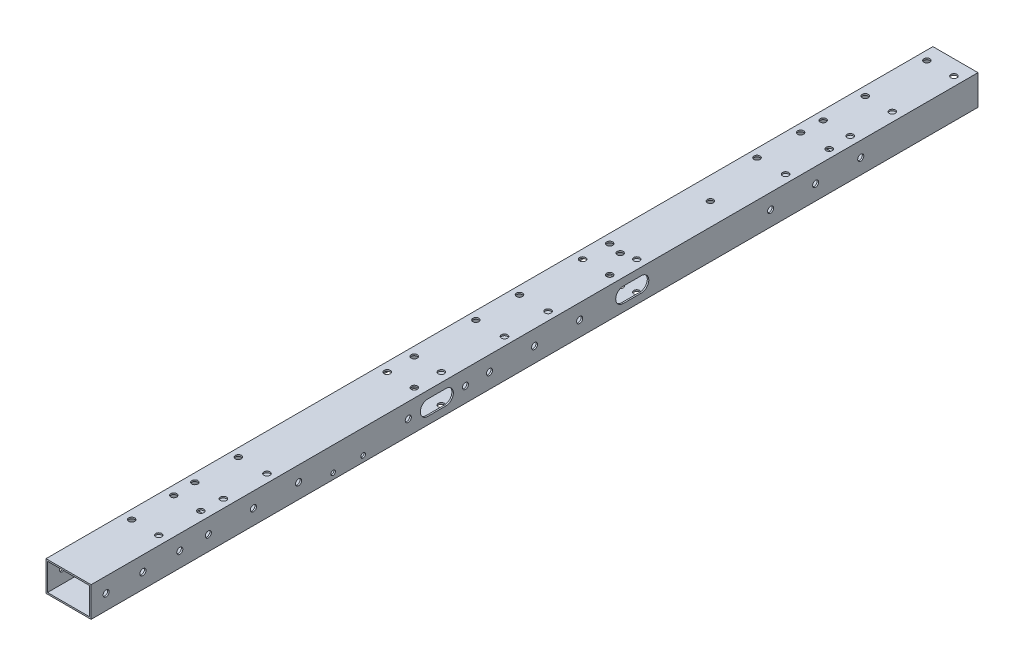
from build123d import *

# Parameters (mm, degrees)
SKETCH_1_W           = 30
SKETCH_1_H           = 20
SKETCH_1_W_2         = 28
SKETCH_1_H_2         = 18
EXTRUDE_1_DEPTH      = 295
SKETCH_5_R           = 2.025
CUT_EXTRUDE_4_DEPTH  = 5
SKETCH_7_R           = 3.8
CUT_EXTRUDE_5_DEPTH  = 5
SKETCH_11_R          = 2.025
CUT_EXTRUDE_9_DEPTH  = 113
SKETCH_18_R          = 2.025
CUT_EXTRUDE_16_DEPTH = 90
SKETCH_21_R          = 2.025
CUT_EXTRUDE_19_DEPTH = 126
SKETCH_22_R          = 2.025
CUT_EXTRUDE_20_DEPTH = 10
SKETCH_26_R          = 1.525
CUT_EXTRUDE_24_DEPTH = 10
SKETCH_27_R          = 1.525
CUT_EXTRUDE_25_DEPTH = 100
CUT_EXTRUDE_26_DEPTH = 100
SKETCH_31_R          = 2.025
CUT_EXTRUDE_29_DEPTH = 50
SKETCH_32_R          = 3.75
CUT_EXTRUDE_30_DEPTH = 10
SKETCH_36_R          = 2.025
CUT_EXTRUDE_33_DEPTH = 37
SKETCH_37_R          = 3.8
CUT_EXTRUDE_34_DEPTH = 10


with BuildPart() as part:
    # 草图1 → 凸台-拉伸1 (new, symmetric)
    with BuildSketch(Plane.XY):
        Rectangle(SKETCH_1_W, SKETCH_1_H)
        Rectangle(SKETCH_1_W_2, SKETCH_1_H_2, mode=Mode.SUBTRACT)
    extrude(amount=EXTRUDE_1_DEPTH, both=True)

    # 草图5 → 切除-拉伸4 (cut, symmetric)
    with BuildSketch(Plane.XZ.offset(-9)):
        with Locations((-9.5, -172.5)):
            Circle(SKETCH_5_R)
        with Locations((9.5, -172.5)):
            Circle(SKETCH_5_R)
        with Locations((-9.5, -201.5)):
            Circle(SKETCH_5_R)
        with Locations((9.5, -201.5)):
            Circle(SKETCH_5_R)
        with Locations((-9.5, -14.5)):
            Circle(SKETCH_5_R)
        with Locations((9.5, -14.5)):
            Circle(SKETCH_5_R)
        with Locations((-9.5, 14.5)):
            Circle(SKETCH_5_R)
        with Locations((9.5, 14.5)):
            Circle(SKETCH_5_R)
        with Locations((-9.5, 172.5)):
            Circle(SKETCH_5_R)
        with Locations((-9.5, 201.5)):
            Circle(SKETCH_5_R)
        with Locations((9.5, 201.5)):
            Circle(SKETCH_5_R)
        with Locations((9.5, 172.5)):
            Circle(SKETCH_5_R)
    extrude(amount=CUT_EXTRUDE_4_DEPTH, both=True, mode=Mode.SUBTRACT)

    # 草图7 → 切除-拉伸5 (cut, symmetric)
    with BuildSketch(Plane(origin=(0, -9, 0), x_dir=(1, 0, 0), z_dir=(0, 1, 0))):
        with Locations((-9.5, 201.5)):
            Circle(SKETCH_7_R)
        with Locations((9.5, 201.5)):
            Circle(SKETCH_7_R)
        with Locations((-9.5, 172.5)):
            Circle(SKETCH_7_R)
        with Locations((9.5, 172.5)):
            Circle(SKETCH_7_R)
        with Locations((-9.5, 14.5)):
            Circle(SKETCH_7_R)
        with Locations((9.5, 14.5)):
            Circle(SKETCH_7_R)
        with Locations((-9.5, -14.5)):
            Circle(SKETCH_7_R)
        with Locations((9.5, -14.5)):
            Circle(SKETCH_7_R)
        with Locations((-9.5, -172.5)):
            Circle(SKETCH_7_R)
        with Locations((9.5, -172.5)):
            Circle(SKETCH_7_R)
        with Locations((-9.5, -201.5)):
            Circle(SKETCH_7_R)
        with Locations((9.5, -201.5)):
            Circle(SKETCH_7_R)
    extrude(amount=CUT_EXTRUDE_5_DEPTH, both=True, mode=Mode.SUBTRACT)

    # 草图11 → 切除-拉伸9 (cut)
    with BuildSketch(Plane(origin=(15, 0, 0), x_dir=(0, 0, -1), z_dir=(1, 0, 0))):
        with Locations((217, 0)):
            Circle(SKETCH_11_R)
        with Locations((187, 0)):
            Circle(SKETCH_11_R)
        with Locations((157, 0)):
            Circle(SKETCH_11_R)
        with Locations((30, 0)):
            Circle(SKETCH_11_R)
        Circle(SKETCH_11_R)
        with Locations((-30, 0)):
            Circle(SKETCH_11_R)
        with Locations((-157, 0)):
            Circle(SKETCH_11_R)
        with Locations((-187, 0)):
            Circle(SKETCH_11_R)
        with Locations((-217, 0)):
            Circle(SKETCH_11_R)
        with Locations((-236, 0)):
            Circle(SKETCH_11_R)
        with Locations((-260.5, 0)):
            Circle(SKETCH_11_R)
        with Locations((-285, 0)):
            Circle(SKETCH_11_R)
    extrude(amount=-CUT_EXTRUDE_9_DEPTH, mode=Mode.SUBTRACT)

    # 草图18 → 切除-拉伸16 (cut)
    with BuildSketch(Plane.XZ.offset(10)):
        with Locations((-9, 74)):
            Circle(SKETCH_18_R)
        with Locations((9, 74)):
            Circle(SKETCH_18_R)
        with Locations((-9, 56)):
            Circle(SKETCH_18_R)
        with Locations((9, 56)):
            Circle(SKETCH_18_R)
    cut_extrude_16 = extrude(amount=-CUT_EXTRUDE_16_DEPTH, mode=Mode.SUBTRACT)

    # 镜向1: 切除-拉伸16 across plane
    add(cut_extrude_16.mirror(Plane.XY), mode=Mode.SUBTRACT)

    # 草图21 → 切除-拉伸19 (cut)
    with BuildSketch(Plane(origin=(15, 0, 0), x_dir=(0, 0, -1), z_dir=(1, 0, 0))):
        with Locations((-46, 0)):
            Circle(SKETCH_21_R)
        with Locations((-84, 0)):
            Circle(SKETCH_21_R)
    extrude(amount=-CUT_EXTRUDE_19_DEPTH, mode=Mode.SUBTRACT)

    # 草图22 → 切除-拉伸20 (cut)
    with BuildSketch(Plane(origin=(0, 10, 0), x_dir=(1, 0, 0), z_dir=(0, 1, 0))):
        with Locations((-9, 285)):
            Circle(SKETCH_22_R)
        with Locations((9, 285)):
            Circle(SKETCH_22_R)
    extrude(amount=-CUT_EXTRUDE_20_DEPTH, mode=Mode.SUBTRACT)

    # 草图26 → 切除-拉伸24 (cut)
    with BuildSketch(Plane.XZ.offset(10)):
        with Locations((-11, 124)):
            Circle(SKETCH_26_R)
        with Locations((-11, 144)):
            Circle(SKETCH_26_R)
        with Locations((11, 144)):
            Circle(SKETCH_26_R)
        with Locations((11, 124)):
            Circle(SKETCH_26_R)
    extrude(amount=-CUT_EXTRUDE_24_DEPTH, mode=Mode.SUBTRACT)

    # 草图27 → 切除-拉伸25 (cut)
    with BuildSketch(Plane.ZY.offset(15)):
        with Locations((134, -6)):
            Circle(SKETCH_27_R)
        with Locations((114, -6)):
            Circle(SKETCH_27_R)
    extrude(amount=-CUT_EXTRUDE_25_DEPTH, mode=Mode.SUBTRACT)

    # 草图28 → 切除-拉伸26 (cut)
    with BuildSketch(Plane(origin=(15, 0, 0), x_dir=(0, 0, -1), z_dir=(1, 0, 0))):
        with BuildLine():
            Line((-71, 5), (-59, 5))
            ThreePointArc((-59, 5), (-54, 0), (-59, -5))
            Line((-59, -5), (-71, -5))
            ThreePointArc((-71, -5), (-76, 0), (-71, 5))
        make_face()
    cut_extrude_26 = extrude(amount=-CUT_EXTRUDE_26_DEPTH, mode=Mode.SUBTRACT)

    # 镜向2: 切除-拉伸26 across plane
    add(cut_extrude_26.mirror(Plane.XY), mode=Mode.SUBTRACT)

    # 草图31 → 切除-拉伸29 (cut)
    with BuildSketch(Plane(origin=(0, 10, 0), x_dir=(1, 0, 0), z_dir=(0, 1, 0))):
        with Locations((0, 72)):
            Circle(SKETCH_31_R)
        with Locations((0, 132)):
            Circle(SKETCH_31_R)
    extrude(amount=-CUT_EXTRUDE_29_DEPTH, mode=Mode.SUBTRACT)

    # 草图32 → 切除-拉伸30 (cut)
    with BuildSketch(Plane.ZY.offset(15)):
        with Locations((46, 0)):
            Circle(SKETCH_32_R)
        with Locations((84, 0)):
            Circle(SKETCH_32_R)
    extrude(amount=-CUT_EXTRUDE_30_DEPTH, mode=Mode.SUBTRACT)

    # 草图36 → 切除-拉伸33 (cut)
    with BuildSketch(Plane(origin=(0, 10, 0), x_dir=(1, 0, 0), z_dir=(0, 1, 0))):
        with Locations((-9, 244)):
            Circle(SKETCH_36_R)
        with Locations((-9, 216)):
            Circle(SKETCH_36_R)
        with Locations((9, 216)):
            Circle(SKETCH_36_R)
        with Locations((9, 244)):
            Circle(SKETCH_36_R)
    cut_extrude_33 = extrude(amount=-CUT_EXTRUDE_33_DEPTH, mode=Mode.SUBTRACT)

    # 草图37 → 切除-拉伸34 (cut)
    with BuildSketch(Plane.XZ.offset(10)):
        with Locations((-9, -216)):
            Circle(SKETCH_37_R)
        with Locations((9, -216)):
            Circle(SKETCH_37_R)
        with Locations((-9, -244)):
            Circle(SKETCH_37_R)
        with Locations((9, -244)):
            Circle(SKETCH_37_R)
    cut_extrude_34 = extrude(amount=-CUT_EXTRUDE_34_DEPTH, mode=Mode.SUBTRACT)

    # 镜向3: 切除-拉伸33, 切除-拉伸34 across plane
    add(cut_extrude_33.mirror(Plane.XY), mode=Mode.SUBTRACT)
    add(cut_extrude_34.mirror(Plane.XY), mode=Mode.SUBTRACT)


solid = part.part
